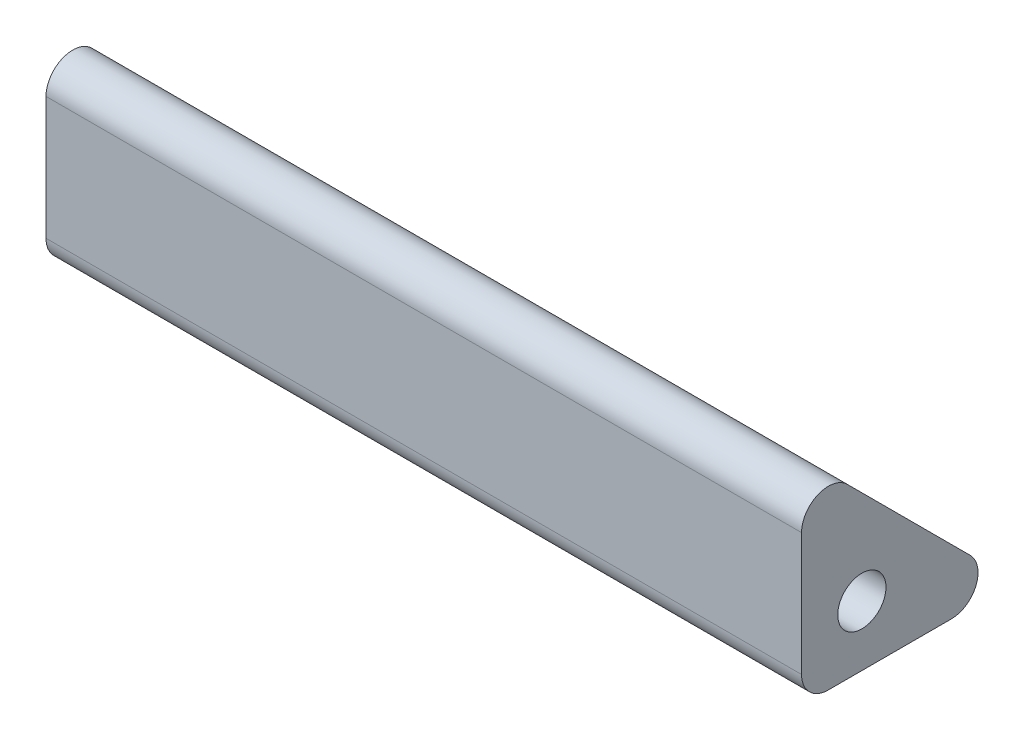
from build123d import *

# Parameters (mm, degrees)
SKETCH1_R           = 0.9
BOSS_EXTRUDE1_DEPTH = 28.2
FILLET1_R           = 1


with BuildPart() as part:
    # Sketch1 → Boss-Extrude1 (new body)
    with BuildSketch(Plane(origin=(0, 0, 0), x_dir=(0, 0, -1), z_dir=(1, 0, 0))):
        Polygon((-2.25, 5.75), (-2.25, -2.25), (5.75, -2.25), align=None)
        Circle(SKETCH1_R, mode=Mode.SUBTRACT)
    extrude(amount=BOSS_EXTRUDE1_DEPTH)

    # Fillet1
    fillet1_edges = [part.edges().sort_by_distance(p)[0] for p in [
        (14.1, -2.25, -5.75),
        (14.1, -2.25, 2.25),
        (14.1, 5.75, 2.25),
    ]]
    fillet(fillet1_edges, radius=FILLET1_R)


solid = part.part
